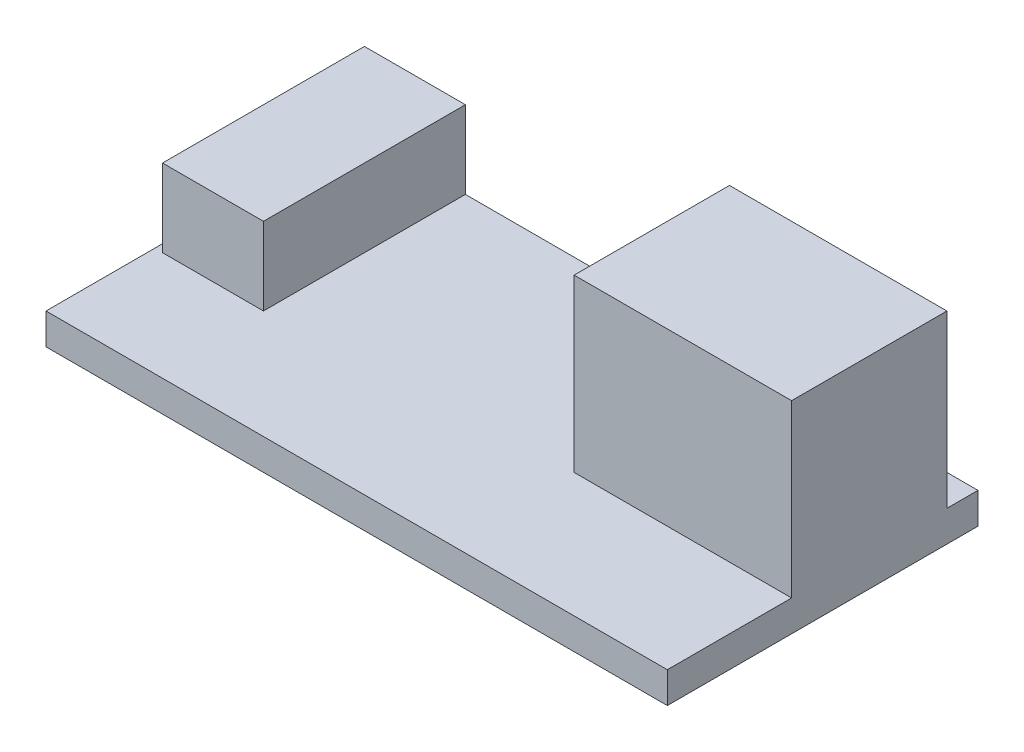
from build123d import *

# Parameters (mm, degrees)
SKETCH1_W           = 40
SKETCH1_H           = 20
BOSS_EXTRUDE1_DEPTH = 2
SKETCH2_W           = 14
SKETCH2_H           = 10
BOSS_EXTRUDE2_DEPTH = 11
SKETCH3_W           = 6.5
SKETCH3_H           = 13
BOSS_EXTRUDE3_DEPTH = 5


with BuildPart() as part:
    # Sketch1 → Boss-Extrude1 (new body)
    with BuildSketch(Plane(origin=(0, 0, 0), x_dir=(1, 0, 0), z_dir=(0, 1, 0))):
        Rectangle(SKETCH1_W, SKETCH1_H)
    extrude(amount=BOSS_EXTRUDE1_DEPTH)

    # Sketch2 → Boss-Extrude2 (add)
    with BuildSketch(Plane(origin=(0, 2, 0), x_dir=(1, 0, 0), z_dir=(0, 1, 0))):
        with Locations((13, 3)):
            Rectangle(SKETCH2_W, SKETCH2_H)
    extrude(amount=BOSS_EXTRUDE2_DEPTH)

    # Sketch3 → Boss-Extrude3 (add)
    with BuildSketch(Plane(origin=(0, 2, 0), x_dir=(1, 0, 0), z_dir=(0, 1, 0))):
        with Locations((-16.25, 3.5)):
            Rectangle(SKETCH3_W, SKETCH3_H)
    extrude(amount=BOSS_EXTRUDE3_DEPTH)


solid = part.part
